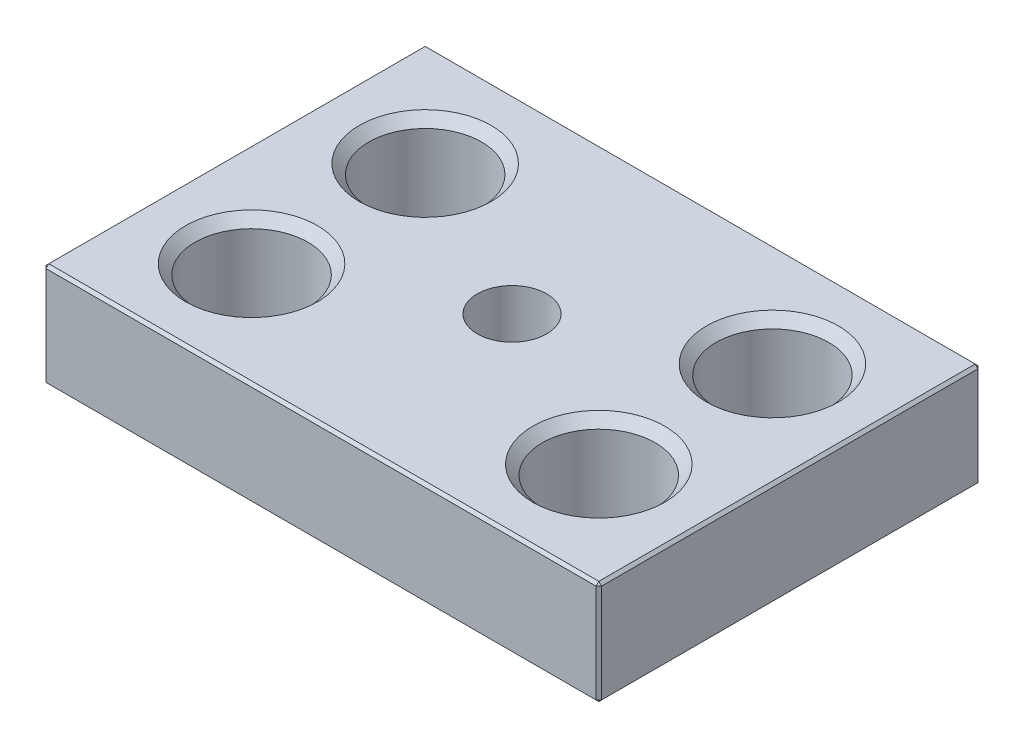
from build123d import *

# Parameters (mm, degrees)
SKETCH1_W                                       = 101.6
SKETCH1_H                                       = 69.85
EXTRUDE1_DEPTH                                  = 19.05
F_13_16_0_8125_DIAMETER_HOLE1_AT_2_COUNT        = 2
F_13_16_0_8125_DIAMETER_HOLE1_AT_2_PITCH        = 31.75
F_13_16_0_8125_DIAMETER_HOLE1_AT_3_COUNT        = 2
F_13_16_0_8125_DIAMETER_HOLE1_AT_3_PITCH        = 70.995158286
F_13_16_0_8125_DIAMETER_HOLE1_AT_4_COUNT        = 2
F_13_16_0_8125_DIAMETER_HOLE1_AT_4_PITCH        = 63.5
CBORE_FOR_10_SOCKET_HEAD_CAP_SCREW1_D           = 5.6134
CBORE_FOR_10_SOCKET_HEAD_CAP_SCREW1_CBORE_D     = 12.7
CBORE_FOR_10_SOCKET_HEAD_CAP_SCREW1_CBORE_DEPTH = 15.24
CHAMFER1_SIZE                                   = 0.508


with BuildPart() as part:
    # Sketch1 → Extrude1 (new body)
    with BuildSketch(Plane(origin=(0, 0, 0), x_dir=(1, 0, 0), z_dir=(0, 1, 0))):
        Rectangle(SKETCH1_W, SKETCH1_H)
    extrude(amount=EXTRUDE1_DEPTH)

    # Sketch3 → 13/16 (0.8125) Diameter Hole1 (revolve, cut)
    with BuildSketch(Plane(origin=(31.75, 19.05, 15.875), x_dir=(0, 0, 1), z_dir=(1, 0, 0))):
        Polygon((0, 0), (0, 19.05), (12.065, 19.05), (10.31875, 17.30375), (10.31875, 1.74625), (12.065, 0), align=None)
    f_13_16_0_8125_diameter_hole1 = revolve(axis=Axis((31.75, 25.4, 15.875), (0, -1, 0)), mode=Mode.SUBTRACT)

    # 13/16 (0.8125) Diameter Hole1 at 2: 13/16 (0.8125) Diameter Hole1 ×2
    with Locations(*[(0, 0, -i * F_13_16_0_8125_DIAMETER_HOLE1_AT_2_PITCH) for i in range(1, F_13_16_0_8125_DIAMETER_HOLE1_AT_2_COUNT)]):
        add(f_13_16_0_8125_diameter_hole1, mode=Mode.SUBTRACT)

    # 13/16 (0.8125) Diameter Hole1 at 3: 13/16 (0.8125) Diameter Hole1 ×2
    with Locations(*[Vector(-0.894427191, 0, -0.447213595) * (i * F_13_16_0_8125_DIAMETER_HOLE1_AT_3_PITCH) for i in range(1, F_13_16_0_8125_DIAMETER_HOLE1_AT_3_COUNT)]):
        add(f_13_16_0_8125_diameter_hole1, mode=Mode.SUBTRACT)

    # 13/16 (0.8125) Diameter Hole1 at 4: 13/16 (0.8125) Diameter Hole1 ×2
    with Locations(*[(-i * F_13_16_0_8125_DIAMETER_HOLE1_AT_4_PITCH, 0, 0) for i in range(1, F_13_16_0_8125_DIAMETER_HOLE1_AT_4_COUNT)]):
        add(f_13_16_0_8125_diameter_hole1, mode=Mode.SUBTRACT)

    # CBORE for #10 Socket Head Cap Screw1 (through all)
    with Locations(Plane(origin=(0, 19.05, 0), x_dir=(-1, 0, 0), z_dir=(0, 1, 0))):
        with Locations((0, 0)):
            CounterBoreHole(CBORE_FOR_10_SOCKET_HEAD_CAP_SCREW1_D / 2, CBORE_FOR_10_SOCKET_HEAD_CAP_SCREW1_CBORE_D / 2, CBORE_FOR_10_SOCKET_HEAD_CAP_SCREW1_CBORE_DEPTH)

    # Chamfer1
    chamfer1_edges = [part.edges().sort_by_distance(p)[0] for p in [
        (50.8, 19.05, 0),
        (0, 19.05, -34.925),
        (-50.8, 19.05, 0),
        (0, 0, -34.925),
        (50.8, 0, 0),
        (0, 0, 34.925),
        (-50.8, 0, 0),
        (0, 19.05, 34.925),
        (-50.8, 9.525, -34.925),
        (50.8, 9.525, -34.925),
        (50.8, 9.525, 34.925),
        (-50.8, 9.525, 34.925),
    ]]
    chamfer(chamfer1_edges, length=CHAMFER1_SIZE)


solid = part.part
